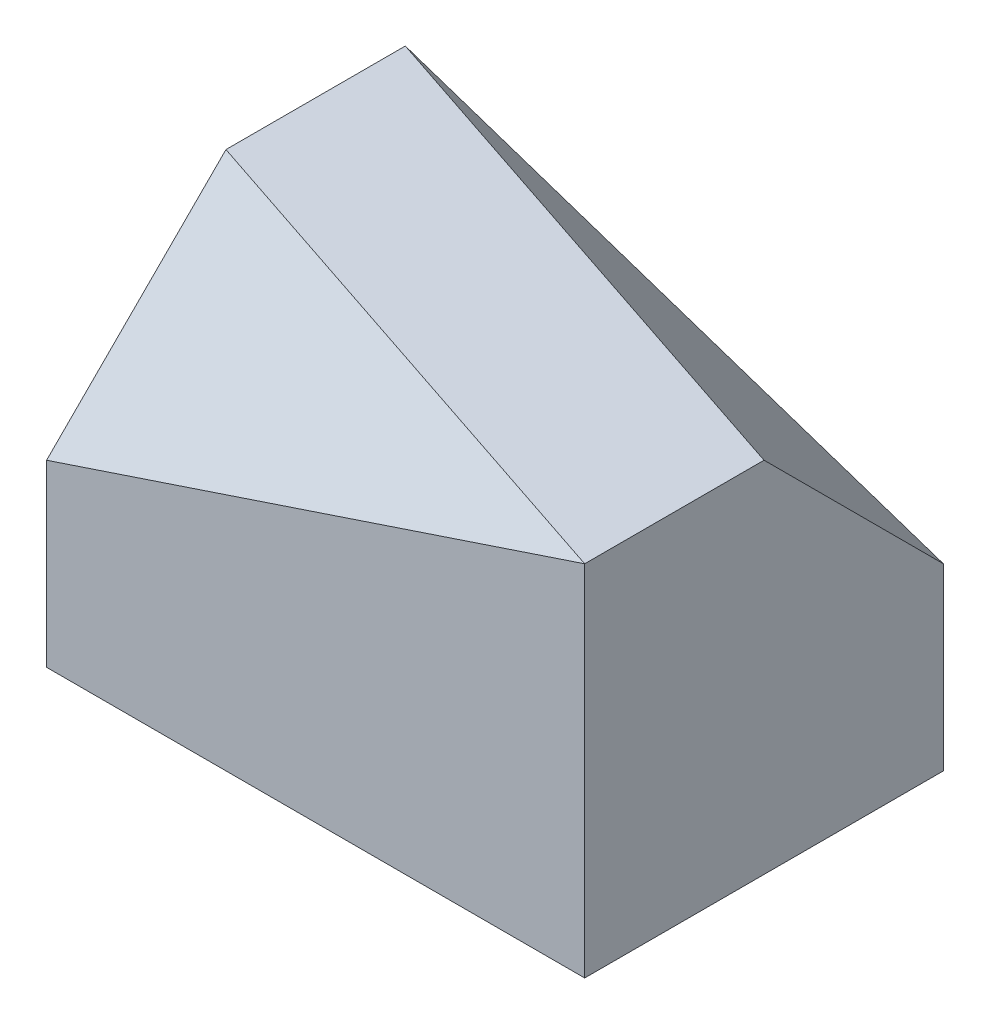
from build123d import *

# Parameters (mm, degrees)
SKETCH_1_W          = 30
SKETCH_1_H          = 20
EXTRUDE_1_DEPTH     = 20
CUT_EXTRUDE_1_DEPTH = 20
SKETCH_10_W         = 32.252295377
SKETCH_10_H         = 15.179180951
CUT_EXTRUDE_2_DEPTH = 25


with BuildPart() as part:
    # 草圖1 → 填料-伸長1 (new body)
    with BuildSketch(Plane(origin=(0, 0, 0), x_dir=(1, 0, 0), z_dir=(0, 1, 0))):
        Rectangle(SKETCH_1_W, SKETCH_1_H)
    extrude(amount=EXTRUDE_1_DEPTH)

    # 草圖6 → 除料-伸長1 (cut)
    with BuildSketch(Plane(origin=(3.947368421, 11.842105263, -11.842105263), x_dir=(0.973328527, -0.162221421, 0.162221421), z_dir=(-0.229415734, -0.688247202, 0.688247202))):
        Polygon((0, 0), (-20.538761547, 0), (-20.538761547, 12.535207186), (11.71353383, 14.625633738), (12.268136792, -0.263322726), align=None)
    extrude(amount=-CUT_EXTRUDE_1_DEPTH, mode=Mode.SUBTRACT)

    # 草圖10 → 除料-伸長2 (cut)
    with BuildSketch(Plane(origin=(-3.947368421, 11.842105263, 11.842105263), x_dir=(0.973328527, 0.162221421, 0.162221421), z_dir=(-0.229415734, 0.688247202, 0.688247202))):
        with Locations((3.943334428, 7.114500239)):
            Rectangle(SKETCH_10_W, SKETCH_10_H)
    extrude(amount=CUT_EXTRUDE_2_DEPTH, mode=Mode.SUBTRACT)


solid = part.part
